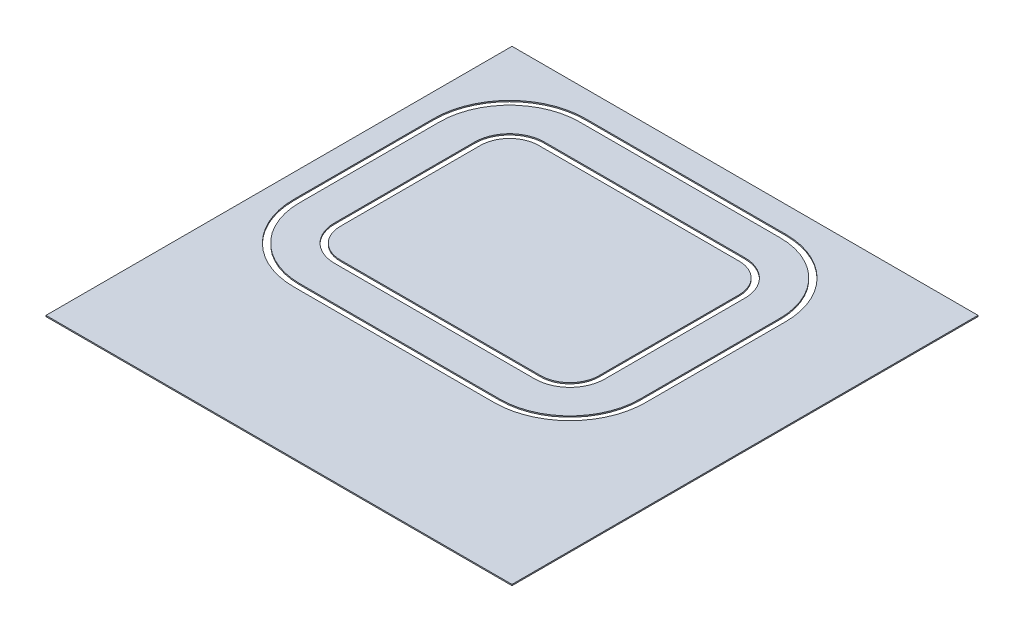
from build123d import *

# Parameters (mm, degrees)
SKETCH1_W             = 4000
SKETCH1_H             = 4000
BOSS_EXTRUDE2_DEPTH   = 10
BOSS_EXTRUDE2_2_DEPTH = 10
BOSS_EXTRUDE2_3_DEPTH = 10


with BuildPart() as part:
    # Sketch1 → Boss-Extrude2 (new body)
    with BuildSketch(Plane(origin=(0, 0, 0), x_dir=(1, 0, 0), z_dir=(0, 1, 0))):
        Rectangle(SKETCH1_W, SKETCH1_H)
        with BuildLine():
            ThreePointArc((-1798.69687513, -74.980124621), (-1608.316282902, -534.599532393), (-1148.69687513, -724.980124621))
            Line((-1148.69687513, -724.980124621), (571.819461789, -724.980124621))
            ThreePointArc((571.819461789, -724.980124621), (1031.43886956, -534.599532393), (1221.819461789, -74.980124621))
            Line((1221.819461789, -74.980124621), (1221.819461789, 1127.660592132))
            ThreePointArc((1221.819461789, 1127.660592132), (1031.43886956, 1587.279999903), (571.819461789, 1777.660592132))
            Line((571.819461789, 1777.660592132), (-1148.69687513, 1777.660592132))
            ThreePointArc((-1148.69687513, 1777.660592132), (-1608.316282902, 1587.279999903), (-1798.69687513, 1127.660592132))
            Line((-1798.69687513, 1127.660592132), (-1798.69687513, -74.980124621))
        make_face(mode=Mode.SUBTRACT)
    extrude(amount=BOSS_EXTRUDE2_DEPTH)


with BuildPart() as body_2:
    # Sketch1 → Boss-Extrude2 2 (new body)
    with BuildSketch(Plane(origin=(0, 0, 0), x_dir=(1, 0, 0), z_dir=(0, 1, 0))):
        with BuildLine():
            Line((-1148.69687513, 1727.660592132), (571.819461789, 1727.660592132))
            ThreePointArc((571.819461789, 1727.660592132), (996.083530501, 1551.924660844), (1171.819461789, 1127.660592132))
            Line((1171.819461789, 1127.660592132), (1171.819461789, -74.980124621))
            ThreePointArc((1171.819461789, -74.980124621), (996.083530501, -499.244193333), (571.819461789, -674.980124621))
            Line((571.819461789, -674.980124621), (-1148.69687513, -674.980124621))
            ThreePointArc((-1148.69687513, -674.980124621), (-1572.960943842, -499.244193333), (-1748.69687513, -74.980124621))
            Line((-1748.69687513, -74.980124621), (-1748.69687513, 1127.660592132))
            ThreePointArc((-1748.69687513, 1127.660592132), (-1572.960943842, 1551.924660844), (-1148.69687513, 1727.660592132))
        make_face()
        with BuildLine():
            ThreePointArc((-1148.69687513, 1427.660592132), (-1360.828909486, 1339.792626488), (-1448.69687513, 1127.660592132))
            Line((-1448.69687513, 1127.660592132), (-1448.69687513, -74.980124621))
            ThreePointArc((-1448.69687513, -74.980124621), (-1360.828909486, -287.112158977), (-1148.69687513, -374.980124621))
            Line((-1148.69687513, -374.980124621), (571.819461789, -374.980124621))
            ThreePointArc((571.819461789, -374.980124621), (783.951496145, -287.112158977), (871.819461789, -74.980124621))
            Line((871.819461789, -74.980124621), (871.819461789, 1127.660592132))
            ThreePointArc((871.819461789, 1127.660592132), (783.951496145, 1339.792626488), (571.819461789, 1427.660592132))
            Line((571.819461789, 1427.660592132), (-1148.69687513, 1427.660592132))
        make_face(mode=Mode.SUBTRACT)
    extrude(amount=BOSS_EXTRUDE2_2_DEPTH)


with BuildPart() as body_3:
    # Sketch1 → Boss-Extrude2 3 (new body)
    with BuildSketch(Plane(origin=(0, 0, 0), x_dir=(1, 0, 0), z_dir=(0, 1, 0))):
        with BuildLine():
            Line((-1148.69687513, 1377.660592132), (571.819461789, 1377.660592132))
            ThreePointArc((571.819461789, 1377.660592132), (748.596157085, 1304.437287428), (821.819461789, 1127.660592132))
            Line((821.819461789, 1127.660592132), (821.819461789, -74.980124621))
            ThreePointArc((821.819461789, -74.980124621), (748.596157085, -251.756819918), (571.819461789, -324.980124621))
            Line((571.819461789, -324.980124621), (-1148.69687513, -324.980124621))
            ThreePointArc((-1148.69687513, -324.980124621), (-1325.473570427, -251.756819918), (-1398.69687513, -74.980124621))
            Line((-1398.69687513, -74.980124621), (-1398.69687513, 1127.660592132))
            ThreePointArc((-1398.69687513, 1127.660592132), (-1325.473570427, 1304.437287428), (-1148.69687513, 1377.660592132))
        make_face()
    extrude(amount=BOSS_EXTRUDE2_3_DEPTH)


solid = Compound([part.part, body_2.part, body_3.part])
